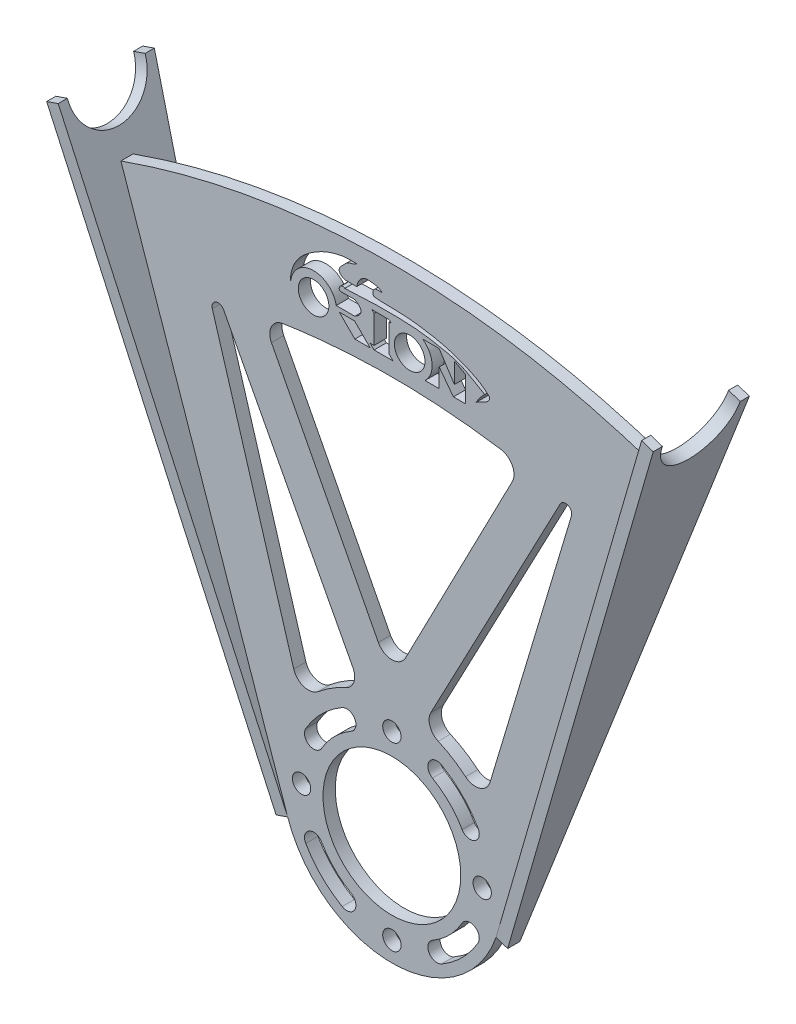
from build123d import *

# Parameters (mm, degrees)
SKETCH1_R           = 22.5
SKETCH1_R_2         = 3
SKETCH1_R_3         = 5
BOSS_EXTRUDE1_DEPTH = 4
CUT_EXTRUDE1_DEPTH  = 10
BOSS_EXTRUDE2_DEPTH = 4
CUT_EXTRUDE3_DEPTH  = 4
FILLET6_R           = 5
FILLET7_R           = 5


with BuildPart() as part:
    # Sketch1 → Boss-Extrude1 (new body)
    with BuildSketch(Plane.XY):
        with BuildLine():
            Line((-100, 180), (-34.041581817, -11.711989898))
            ThreePointArc((-34.041581817, -11.711989898), (0, -36), (34.041581817, -11.711989898))
            Line((34.041581817, -11.711989898), (100, 180))
            Line((100, 180), (80, 180))
            Line((80, 180), (77.16044559, 171.746669473))
            ThreePointArc((77.16044559, 171.746669473), (73.512492253, 166.859566803), (67.704450641, 165))
            Line((67.704450641, 165), (-67.704450641, 165))
            ThreePointArc((-67.704450641, 165), (-73.512492253, 166.859566803), (-77.16044559, 171.746669473))
            Line((-77.16044559, 171.746669473), (-80, 180))
            Line((-80, 180), (-100, 180))
        make_face()
        Circle(SKETCH1_R, mode=Mode.SUBTRACT)
        with Locations((-29.5, 0)):
            Circle(SKETCH1_R_2, mode=Mode.SUBTRACT)
        with Locations((-25.583118726, 139.563011578)):
            Circle(SKETCH1_R_3, mode=Mode.SUBTRACT)
        with Locations((5.820989192, 139.563011578)):
            Circle(SKETCH1_R_3, mode=Mode.SUBTRACT)
        with Locations((0, 29.5)):
            Circle(SKETCH1_R_2, mode=Mode.SUBTRACT)
        with Locations((29.5, 0)):
            Circle(SKETCH1_R_2, mode=Mode.SUBTRACT)
        with Locations((0, -29.5)):
            Circle(SKETCH1_R_2, mode=Mode.SUBTRACT)
        with BuildLine():
            Line((-15.382608501, 149.612616147), (-11.49153184, 149.612616147))
            add(Edge.make_bspline(
                [(-11.49153184, 149.612616147), (-11.27981716, 150.64344279), (-10.672037401, 152.373710024), (-8.464069822, 153.499523115), (-5.984183786, 153.256464177), (-4.118352288, 152.99159833), (-3.18473981, 152.113618001)],
                knots=[0, 0, 0, 0, 0.307612557, 0.470619464, 0.661138392, 1, 1, 1, 1], degree=3))
            add(Edge.make_bspline(
                [(-3.18473981, 152.113618001), (-3.837194089, 151.952154825), (-6.149562334, 152.580918526), (-6.391494121, 150.149073376), (-5.817373341, 149.612616147)],
                knots=[0, 0, 0, 0, 0.521430257, 1, 1, 1, 1], degree=3))
            add(Edge.make_bspline(
                [(-5.817373341, 149.612616147), (-2.857250016, 149.252808607), (1.722458008, 149.451495054), (7.878417039, 148.922829611), (12.629618642, 148.174265546), (17.40086152, 147.270004117), (24.083480831, 144.907975752), (29.170409237, 142.837354355), (31.960917819, 140.003503761)],
                knots=[0, 0, 0, 0, 0.224335437, 0.345081839, 0.465662563, 0.587504151, 0.710743316, 1, 1, 1, 1], degree=3))
            add(Edge.make_bspline(
                [(31.960917819, 140.003503761), (32.028185562, 138.920857444), (30.21133678, 137.639492769), (28.367589333, 137.108149912), (27.514389963, 136.378400886)],
                knots=[0, 0, 0, 0, 0.47054422, 1, 1, 1, 1], degree=3))
            add(Edge.make_bspline(
                [(27.514389963, 136.378400886), (28.646185013, 138.390357103), (30.312414493, 140.003503761)],
                knots=[0, 0, 0, 1, 1, 1], degree=2))
            add(Edge.make_bspline(
                [(-15.382608501, 147.155491519), (-11.192223223, 147.410851752), (-5.031533761, 147.715167044), (3.351930184, 147.628806348), (9.758459625, 147.299231901), (16.053134772, 146.147590629), (23.290177067, 144.57932534), (27.548763548, 141.456364255), (30.312414493, 140.003503761)],
                knots=[0, 0, 0, 0, 0.267113571, 0.391845829, 0.533350742, 0.674066548, 0.799249382, 1, 1, 1, 1], degree=3))
            add(Edge.make_bspline(
                [(-15.382608501, 147.155491519), (-16.952480053, 148.339489384), (-18.112830174, 145.259730098), (-16.216275785, 145.619788626)],
                knots=[0, 0, 0, 0, 1, 1, 1, 1], degree=3))
            Line((-16.216275785, 145.619788626), (-12.094456709, 145.619788626))
            add(Edge.make_bspline(
                [(-12.094456709, 145.619788626), (-8.052316023, 143.290686032), (-12.094456709, 140.918443715)],
                knots=[0, 0, 0, 1, 1, 1], degree=2))
            Line((-12.094456709, 140.918443715), (-18.179887018, 140.918443715))
            ThreePointArc((-18.179887018, 140.918443715), (-26.263622132, 147.058473613), (-33.109408383, 139.563011578))
            add(Edge.make_bspline(
                [(-33.109408383, 139.563011578), (-33.348418947, 142.667287275), (-31.680682063, 147.58353643), (-26.679528333, 151.755879356), (-20.536034343, 155.262855997), (-15.220153743, 156.401042143), (-11.49153184, 156.070299073)],
                knots=[0, 0, 0, 0, 0.30146529, 0.480013068, 0.632553451, 1, 1, 1, 1], degree=3))
            add(Edge.make_bspline(
                [(-11.49153184, 156.070299073), (-12.424160302, 155.310395818), (-14.587560194, 155.317010596), (-15.862559314, 153.405949418), (-17.013941308, 152.535861147), (-17.547440354, 150.684796556), (-16.058847922, 149.84722894), (-15.382608501, 149.612616147)],
                knots=[0, 0, 0, 0, 0.349428498, 0.525829333, 0.63245289, 0.767128986, 1, 1, 1, 1], degree=3))
        make_face(mode=Mode.SUBTRACT)
        with BuildLine():
            Line((39.408029471, 120), (-39.408029471, 120))
            Line((-39.408029471, 120), (-4.439541067, 52.505622088))
            ThreePointArc((-4.439541067, 52.505622088), (0, 49.805725373), (4.439541067, 52.505622088))
            Line((4.439541067, 52.505622088), (39.408029471, 120))
        make_face(mode=Mode.SUBTRACT)
        Polygon((-17.181574746, 139.563011578), (-12.094456709, 134.47589354), (-7.094057067, 134.47589354), (-12.181175104, 139.563011578), align=None, mode=Mode.SUBTRACT)
        Polygon((-6.519408949, 145.619788626), (-5.817373341, 144.917753018), (-5.817373341, 135.804904347), (-7.094057067, 135.804904347), (-5.817373341, 134.528220621), (0.3955283, 134.528220621), (-0.881155426, 135.804904347), (-0.881155426, 144.917753018), (-0.242813563, 144.917753018), (-0.881155426, 145.556094881), align=None, mode=Mode.SUBTRACT)
        with BuildLine():
            Line((10.046131922, 145.556094881), (15.449713215, 145.556094881))
            Line((15.449713215, 145.556094881), (20.425917266, 137.881043689))
            Line((20.425917266, 137.881043689), (20.425917266, 144.534187423))
            Line((20.425917266, 144.534187423), (24.063982412, 142.537929407))
            Line((24.063982412, 142.537929407), (24.063982412, 134.21690084))
            Line((24.063982412, 134.21690084), (20.09138254, 134.21690084))
            Line((20.09138254, 134.21690084), (15.449713215, 140.363976432))
            Line((15.449713215, 140.363976432), (15.449713215, 134.21690084))
            Line((15.449713215, 134.21690084), (10.839751844, 134.21690084))
            ThreePointArc((10.839751844, 134.21690084), (13.135821866, 140.074970092), (10.046131922, 145.556094881))
        make_face(mode=Mode.SUBTRACT)
        with BuildLine():
            Line((-58.6711489, 119.842439614), (-32.069489259, 31.152425455))
            ThreePointArc((-32.069489259, 31.152425455), (-28.715873504, 27.799425528), (-24.070833889, 28.754911857))
            ThreePointArc((-24.070833889, 28.754911857), (-19.800374557, 31.846430999), (-15.138563888, 34.308510364))
            ThreePointArc((-15.138563888, 34.308510364), (-12.435007965, 37.23907385), (-12.734175942, 41.214990788))
            Line((-12.734175942, 41.214990788), (-54.986319307, 121.349834424))
            ThreePointArc((-54.986319307, 121.349834424), (-57.512714983, 122.268129632), (-58.6711489, 119.842439614))
        make_face(mode=Mode.SUBTRACT)
        with BuildLine():
            Line((58.6711489, 119.842439614), (32.069489259, 31.152425455))
            ThreePointArc((32.069489259, 31.152425455), (28.715873504, 27.799425528), (24.070833889, 28.754911857))
            ThreePointArc((24.070833889, 28.754911857), (19.800374557, 31.846430999), (15.138563888, 34.308510364))
            ThreePointArc((15.138563888, 34.308510364), (12.435007965, 37.23907385), (12.734175942, 41.214990788))
            Line((12.734175942, 41.214990788), (54.986319307, 121.349834424))
            ThreePointArc((54.986319307, 121.349834424), (57.512714983, 122.268129632), (58.6711489, 119.842439614))
        make_face(mode=Mode.SUBTRACT)
        with BuildLine():
            ThreePointArc((-28.145825623, 16.25), (-27.047749412, 12.151923789), (-22.9496732, 13.25))
            ThreePointArc((-22.9496732, 13.25), (-18.738329701, 18.738329701), (-13.25, 22.9496732))
            ThreePointArc((-13.25, 22.9496732), (-12.151923789, 27.047749412), (-16.25, 28.145825623))
            ThreePointArc((-16.25, 28.145825623), (-22.980970389, 22.980970389), (-28.145825623, 16.25))
        make_face(mode=Mode.SUBTRACT)
        with BuildLine():
            ThreePointArc((16.25, 28.145825623), (12.151923789, 27.047749412), (13.25, 22.9496732))
            ThreePointArc((13.25, 22.9496732), (18.738329701, 18.738329701), (22.9496732, 13.25))
            ThreePointArc((22.9496732, 13.25), (27.047749412, 12.151923789), (28.145825623, 16.25))
            ThreePointArc((28.145825623, 16.25), (22.980970389, 22.980970389), (16.25, 28.145825623))
        make_face(mode=Mode.SUBTRACT)
        with BuildLine():
            ThreePointArc((28.145825623, -16.25), (27.047749412, -12.151923789), (22.9496732, -13.25))
            ThreePointArc((22.9496732, -13.25), (18.738329701, -18.738329701), (13.25, -22.9496732))
            ThreePointArc((13.25, -22.9496732), (12.151923789, -27.047749412), (16.25, -28.145825623))
            ThreePointArc((16.25, -28.145825623), (22.980970389, -22.980970389), (28.145825623, -16.25))
        make_face(mode=Mode.SUBTRACT)
        with BuildLine():
            ThreePointArc((-16.25, -28.145825623), (-12.151923789, -27.047749412), (-13.25, -22.9496732))
            ThreePointArc((-13.25, -22.9496732), (-18.738329701, -18.738329701), (-22.9496732, -13.25))
            ThreePointArc((-22.9496732, -13.25), (-27.047749412, -12.151923789), (-28.145825623, -16.25))
            ThreePointArc((-28.145825623, -16.25), (-22.980970389, -22.980970389), (-16.25, -28.145825623))
        make_face(mode=Mode.SUBTRACT)
    extrude(amount=BOSS_EXTRUDE1_DEPTH)

    # Sketch8 → Cut-Extrude1 (cut)
    with BuildSketch(Plane.XY.offset(4)):
        with BuildLine():
            Line((-200.939906976, 66.504969732), (-195.858068428, 212.728625835))
            Line((-195.858068428, 212.728625835), (191.939925307, 202.297123321))
            Line((191.939925307, 202.297123321), (200.939906976, 66.504969732))
            add(Edge.make_bspline(
                [(200.939906976, 66.504969732), (198.086044005, 70.168374358), (192.167909082, 77.312723957), (179.412739177, 90.970597856), (161.877942884, 106.698919131), (138.556571012, 123.170103287), (104.856462623, 141.602609275), (58.710060456, 157.496424827), (0, 163.981734689), (-58.710060456, 157.496424827), (-104.856462623, 141.602609275), (-138.556571012, 123.170103287), (-161.877942884, 106.698919131), (-179.412739177, 90.970597856), (-192.167909082, 77.312723957), (-198.086044005, 70.168374358), (-200.939906976, 66.504969732)],
                knots=[0.628759044, 0.628759044, 0.628759044, 0.628759044, 0.687636374, 0.746513704, 0.864268364, 0.982023025, 1.099777685, 1.335287006, 1.570796327, 1.806305648, 2.041814968, 2.159569629, 2.277324289, 2.39507895, 2.45395628, 2.51283361, 2.51283361, 2.51283361, 2.51283361], degree=3))
        make_face()
    extrude(amount=-CUT_EXTRUDE1_DEPTH, mode=Mode.SUBTRACT)

    # Sketch11 → Boss-Extrude2 (add)
    with BuildSketch(Plane(origin=(-34.041581817, -11.711989898, 0), x_dir=(0, 0, 1), z_dir=(-0.945599495, -0.325333053, 0))):
        with BuildLine():
            Line((0, 0), (-13.7, 188.297616832))
            Line((-13.7, 188.297616832), (-10.7, 188.297616832))
            ThreePointArc((-10.7, 188.297616832), (2, 175.597616832), (14.7, 188.297616832))
            Line((14.7, 188.297616832), (17.7, 188.297616832))
            Line((17.7, 188.297616832), (4, 0))
            Line((4, 0), (0, 0))
        make_face()
    boss_extrude2 = extrude(amount=BOSS_EXTRUDE2_DEPTH)

    # Mirror1: Boss-Extrude2 across plane
    add(boss_extrude2.mirror(Plane(origin=(0, 0, 0), x_dir=(0, 0, 1), z_dir=(1, 0, 0))))

    # Sketch16 → Cut-Extrude3 (cut)
    with BuildSketch(Plane.XY.offset(4)):
        with BuildLine():
            Line((-39.408029471, 120), (-42.486466464, 125.941840762))
            add(Edge.make_bspline(
                [(-42.486466464, 125.941840762), (-41.532355559, 126.117629787), (-40.576779331, 126.28751419), (-26.571726774, 128.687091008), (-13.275477752, 129.819964735), (13.275477761, 129.819964735), (26.571726783, 128.687091007), (40.576779336, 126.287514189), (41.532355562, 126.117629786), (42.486466464, 125.941840762)],
                knots=[0.231664182, 0.231664182, 0.231664182, 0.231664182, 0.25, 0.25, 0.5, 0.5, 0.75, 0.75, 0.768335818, 0.768335818, 0.768335818, 0.768335818], degree=3))
            Line((42.486466464, 125.941840762), (39.408029471, 120))
            Line((39.408029471, 120), (-39.408029471, 120))
        make_face()
    extrude(amount=-CUT_EXTRUDE3_DEPTH, mode=Mode.SUBTRACT)

    # Fillet6
    fillet6_edges = [part.edges().sort_by_distance(p)[0] for p in [
        (-42.486466464, 125.941840762, 2),
    ]]
    fillet(fillet6_edges, radius=FILLET6_R)

    # Fillet7
    fillet7_edges = [part.edges().sort_by_distance(p)[0] for p in [
        (42.486466464, 125.941840762, 2),
    ]]
    fillet(fillet7_edges, radius=FILLET7_R)


solid = part.part
